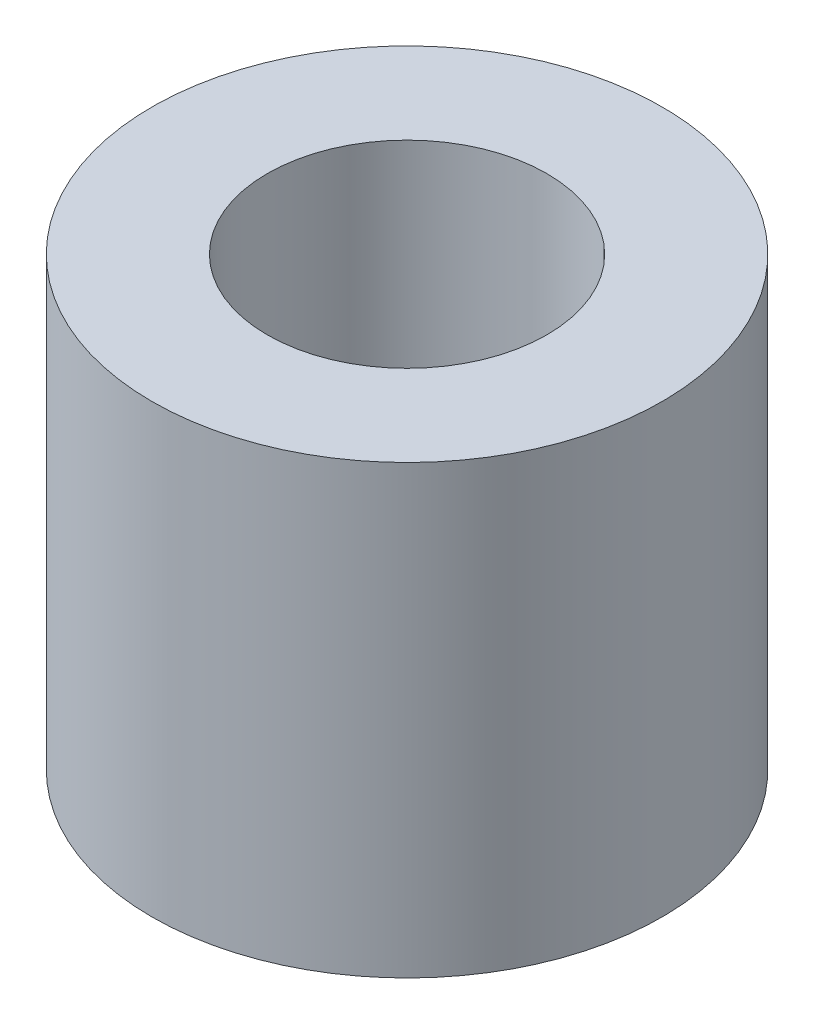
from build123d import *

# Parameters (mm, degrees)
SKETCH1_R           = 4
SKETCH1_R_2         = 2.191431444
BOSS_EXTRUDE1_DEPTH = 7


with BuildPart() as part:
    # Sketch1 → Boss-Extrude1 (new body)
    with BuildSketch(Plane(origin=(0, 0, 0), x_dir=(1, 0, 0), z_dir=(0, 1, 0))):
        Circle(SKETCH1_R)
        Circle(SKETCH1_R_2, mode=Mode.SUBTRACT)
    extrude(amount=BOSS_EXTRUDE1_DEPTH)


solid = part.part
